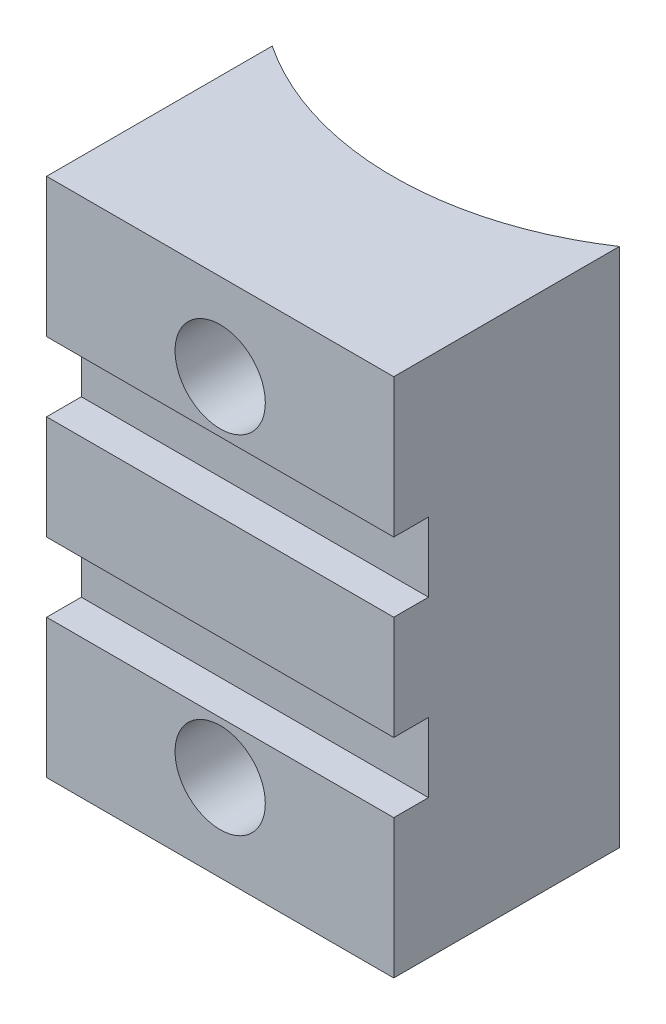
from build123d import *

# Parameters (mm, degrees)
BOSS_EXTRUDE1_DEPTH = 30
CUT_EXTRUDE1_REACH  = 15
SKETCH2_R           = 2.6
CUT_EXTRUDE2_REACH  = 19.5
CUT_EXTRUDE2_START  = -4.5
SKETCH3_R           = 4.4
CUT_EXTRUDE3_REACH  = 22
SKETCH4_W           = 2
SKETCH4_H           = 4


with BuildPart() as part:
    # Sketch1 → Boss-Extrude1 (new body)
    with BuildSketch(Plane(origin=(0, 0, 0), x_dir=(1, 0, 0), z_dir=(0, 1, 0))):
        with BuildLine():
            Line((0, 0), (20, 0))
            Line((20, 0), (20, 13))
            ThreePointArc((20, 13), (10, 9.966629547), (0, 13))
            Line((0, 13), (0, 0))
        make_face()
    extrude(amount=BOSS_EXTRUDE1_DEPTH)

    # Sketch2 → Cut-Extrude1 (cut, up to next)
    with BuildSketch(Plane.XY, mode=Mode.PRIVATE) as cut_extrude1_sk1:
        with Locations((10, 25)):
            Circle(SKETCH2_R)
    cut_extrude1_tool1 = extrude(cut_extrude1_sk1.sketch, amount=-CUT_EXTRUDE1_REACH, mode=Mode.PRIVATE) & part.part
    add(cut_extrude1_tool1.solids().sort_by_distance((10, 25, 0))[0], mode=Mode.SUBTRACT)
    # Sketch2 → Cut-Extrude1 (cut, up to next)
    with BuildSketch(Plane.XY, mode=Mode.PRIVATE) as cut_extrude1_sk2:
        with Locations((10, 5)):
            Circle(SKETCH2_R)
    cut_extrude1_tool2 = extrude(cut_extrude1_sk2.sketch, amount=-CUT_EXTRUDE1_REACH, mode=Mode.PRIVATE) & part.part
    add(cut_extrude1_tool2.solids().sort_by_distance((10, 5, 0))[0], mode=Mode.SUBTRACT)

    # Sketch3 → Cut-Extrude2 (cut, up to next)
    with BuildSketch(Plane.XY.offset(CUT_EXTRUDE2_START), mode=Mode.PRIVATE) as cut_extrude2_sk1:
        with Locations((10, 25)):
            Circle(SKETCH3_R)
    cut_extrude2_tool1 = extrude(cut_extrude2_sk1.sketch, amount=-CUT_EXTRUDE2_REACH, mode=Mode.PRIVATE) & part.part
    add(cut_extrude2_tool1.solids().sort_by_distance((10, 25, -4.5))[0], mode=Mode.SUBTRACT)
    # Sketch3 → Cut-Extrude2 (cut, up to next)
    with BuildSketch(Plane.XY.offset(CUT_EXTRUDE2_START), mode=Mode.PRIVATE) as cut_extrude2_sk2:
        with Locations((10, 5)):
            Circle(SKETCH3_R)
    cut_extrude2_tool2 = extrude(cut_extrude2_sk2.sketch, amount=-CUT_EXTRUDE2_REACH, mode=Mode.PRIVATE) & part.part
    add(cut_extrude2_tool2.solids().sort_by_distance((10, 5, -4.5))[0], mode=Mode.SUBTRACT)

    # Sketch4 → Cut-Extrude3 (cut, up to next)
    with BuildSketch(Plane(origin=(20, 0, 0), x_dir=(0, 0, -1), z_dir=(1, 0, 0)), mode=Mode.PRIVATE) as cut_extrude3_sk1:
        with Locations((1, 20)):
            Rectangle(SKETCH4_W, SKETCH4_H)
    cut_extrude3_tool1 = extrude(cut_extrude3_sk1.sketch, amount=-CUT_EXTRUDE3_REACH, mode=Mode.PRIVATE) & part.part
    add(cut_extrude3_tool1.solids().sort_by_distance((20, 20, -1))[0], mode=Mode.SUBTRACT)
    # Sketch4 → Cut-Extrude3 (cut, up to next)
    with BuildSketch(Plane(origin=(20, 0, 0), x_dir=(0, 0, -1), z_dir=(1, 0, 0)), mode=Mode.PRIVATE) as cut_extrude3_sk2:
        with Locations((1, 10)):
            Rectangle(SKETCH4_W, SKETCH4_H)
    cut_extrude3_tool2 = extrude(cut_extrude3_sk2.sketch, amount=-CUT_EXTRUDE3_REACH, mode=Mode.PRIVATE) & part.part
    add(cut_extrude3_tool2.solids().sort_by_distance((20, 10, -1))[0], mode=Mode.SUBTRACT)


solid = part.part
